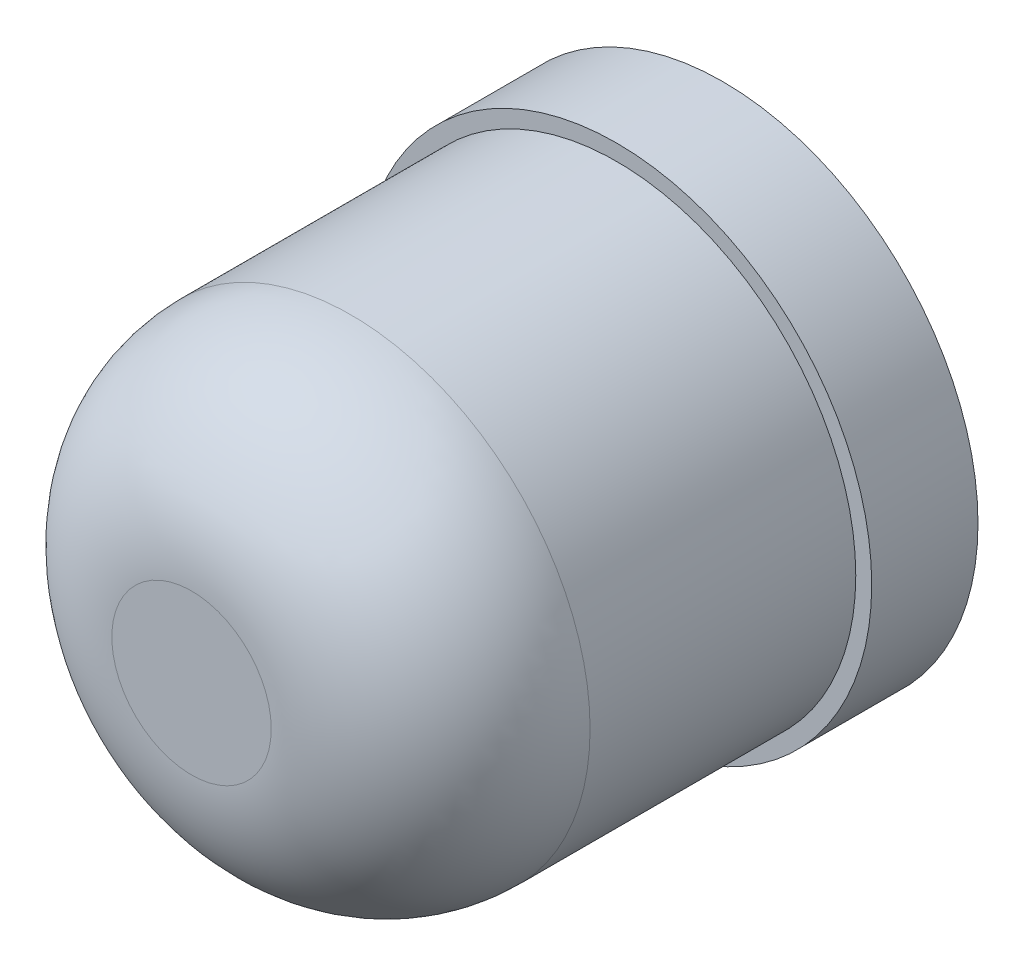
from build123d import *

# Parameters (mm, degrees)
SKETCH_1_R      = 2.25
EXTRUDE_1_DEPTH = 4
SKETCH_2_R      = 2.4
EXTRUDE_2_DEPTH = 1
FILLET_8_R      = 1.5


with BuildPart() as part:
    # Эскиз1 → Бобышка-Вытянуть1 (new body)
    with BuildSketch(Plane.XY):
        with Locations((0, 4.957015904)):
            Circle(SKETCH_1_R)
    extrude(amount=EXTRUDE_1_DEPTH)

    # Эскиз2 → Бобышка-Вытянуть2 (add)
    with BuildSketch(Plane(origin=(0, 0, 0), x_dir=(-1, 0, 0), z_dir=(0, 0, -1))):
        with Locations((0, 4.957015904)):
            Circle(SKETCH_2_R)
    extrude(amount=EXTRUDE_2_DEPTH)

    # Скругление8
    fillet_8_edges = [part.edges().sort_by_distance(p)[0] for p in [
        (-2.25, 4.957015904, 4),
    ]]
    fillet(fillet_8_edges, radius=FILLET_8_R)


solid = part.part
